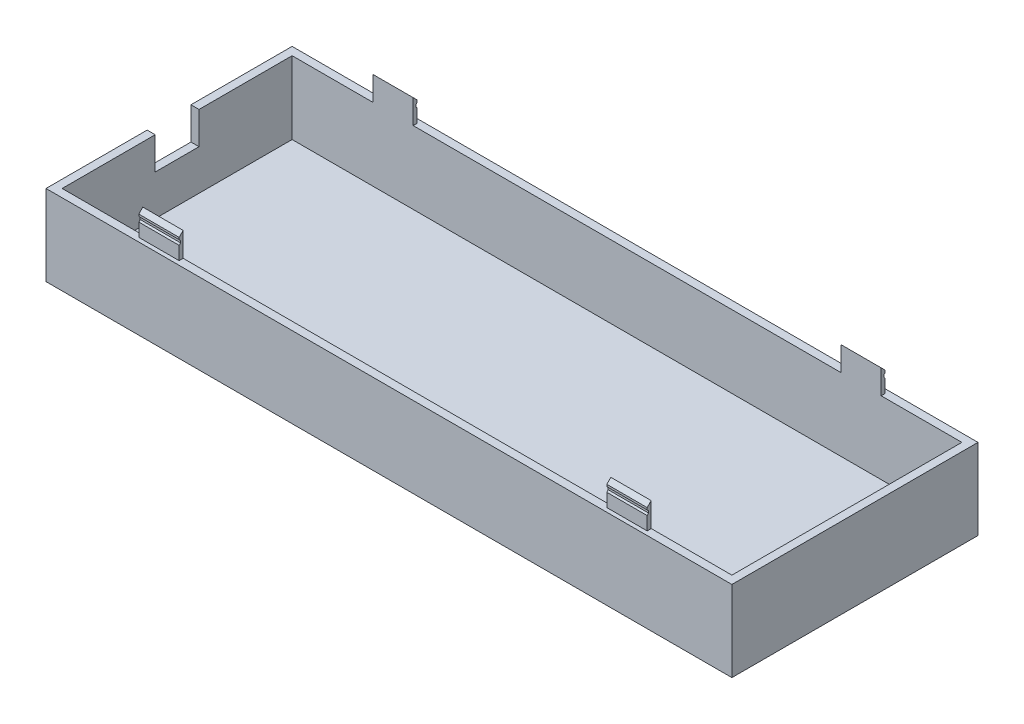
from build123d import *

# Parameters (mm, degrees)
SKETCH1_W           = 170
SKETCH1_H           = 61
BOSS_EXTRUDE1_DEPTH = 20
SKETCH2_W           = 166
SKETCH2_H           = 57
CUT_EXTRUDE1_DEPTH  = 18
SKETCH3_W           = 10
SKETCH3_H           = 1
BOSS_EXTRUDE2_DEPTH = 6
CUT_EXTRUDE2_DEPTH  = 200
SKETCH5_W           = 10.85
SKETCH5_H           = 8
CUT_EXTRUDE3_DEPTH  = 5


with BuildPart() as part:
    # Sketch1 → Boss-Extrude1 (new body)
    with BuildSketch(Plane(origin=(0, 0, 0), x_dir=(1, 0, 0), z_dir=(0, 1, 0))):
        with Locations((85, 30.5)):
            Rectangle(SKETCH1_W, SKETCH1_H)
    extrude(amount=BOSS_EXTRUDE1_DEPTH)

    # Sketch2 → Cut-Extrude1 (cut)
    with BuildSketch(Plane(origin=(0, 20, 0), x_dir=(1, 0, 0), z_dir=(0, 1, 0))):
        with Locations((85, 30.5)):
            Rectangle(SKETCH2_W, SKETCH2_H)
    extrude(amount=-CUT_EXTRUDE1_DEPTH, mode=Mode.SUBTRACT)

    # Sketch3 → Boss-Extrude2 (add)
    with BuildSketch(Plane(origin=(0, 20, 0), x_dir=(1, 0, 0), z_dir=(0, 1, 0))):
        with Locations((27, 1.5)):
            Rectangle(SKETCH3_W, SKETCH3_H)
        with Locations((143, 1.5)):
            Rectangle(SKETCH3_W, SKETCH3_H)
        with Locations((27, 59.5)):
            Rectangle(SKETCH3_W, SKETCH3_H)
        with Locations((143, 59.5)):
            Rectangle(SKETCH3_W, SKETCH3_H)
    extrude(amount=BOSS_EXTRUDE2_DEPTH)

    # Sketch4 → Cut-Extrude2 (cut)
    with BuildSketch(Plane.ZY.offset(-22)):
        Polygon((-60, 25), (-59, 26), (-60, 26), align=None)
        Polygon((-59.646446609, 24.146446609), (-60, 24.5), (-60, 23.292893219), (-59.646446609, 23.646446609), align=None)
        Polygon((-1, 26), (-2, 26), (-1, 25), align=None)
        Polygon((-1, 23.292893219), (-1, 24.5), (-1.353553391, 24.146446609), (-1.353553391, 23.646446609), align=None)
    extrude(amount=-CUT_EXTRUDE2_DEPTH, mode=Mode.SUBTRACT)

    # Sketch5 → Cut-Extrude3 (cut)
    with BuildSketch(Plane.ZY):
        with Locations((-30.5, 16)):
            Rectangle(SKETCH5_W, SKETCH5_H)
    extrude(amount=-CUT_EXTRUDE3_DEPTH, mode=Mode.SUBTRACT)


solid = part.part
